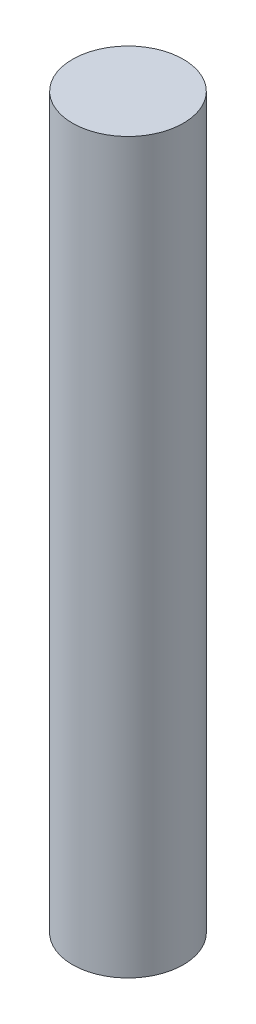
from build123d import *

# Parameters (mm, degrees)
SKETCH2_R           = 1.825
BOSS_EXTRUDE1_DEPTH = 24


with BuildPart() as part:
    # Sketch2 → Boss-Extrude1 (new body)
    with BuildSketch(Plane(origin=(0, 0, 0), x_dir=(1, 0, 0), z_dir=(0, 1, 0))):
        Circle(SKETCH2_R)
    extrude(amount=BOSS_EXTRUDE1_DEPTH)


solid = part.part
